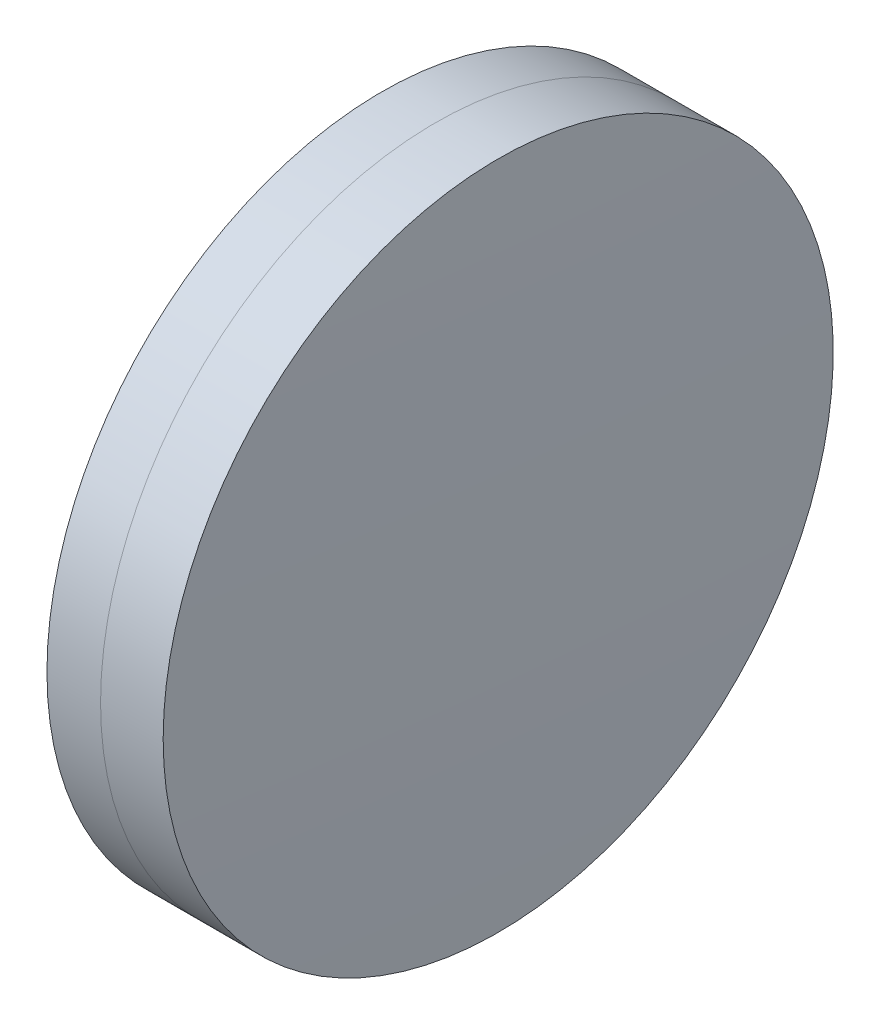
from build123d import *


with BuildPart() as part:
    # 草图1 one side → 旋转1 (revolve)
    with BuildSketch(Plane(origin=(0, 0, 0), x_dir=(1, 0, 0), z_dir=(0, 1, 0)), mode=Mode.PRIVATE) as revolve_1_sk:
        with BuildLine():
            ThreePointArc((174.787921874, 12.5), (174.549245088, 6.25202537), (174.469668974, 0))
            Line((174.469668974, 0), (177.269668974, 0))
            ThreePointArc((177.269668974, 0), (177.149171853, 6.254641088), (176.787859316, 12.5))
            Line((176.787859316, 12.5), (174.787921874, 12.5))
        make_face()
    revolve(revolve_1_sk.sketch.rotate(Axis((-9.702612178, 0, 0), (1, 0, 0)), 180), axis=Axis((-9.702612178, 0, 0), (1, 0, 0)))  # turned: the seam where the file's is


with BuildPart() as body_2:
    # 草图2 one side → 旋转3 (revolve)
    with BuildSketch(Plane(origin=(0, 0, 0), x_dir=(1, 0, 0), z_dir=(0, 1, 0)), mode=Mode.PRIVATE) as revolve_3_sk:
        with BuildLine():
            Line((179.123844569, 12.5), (176.787859316, 12.5))
            ThreePointArc((176.787859316, 12.5), (177.149171853, 6.254641088), (177.269668974, 0))
            Line((177.269668974, 0), (179.269668974, 0))
            ThreePointArc((179.269668974, 0), (179.233211632, 6.250425281), (179.123844569, 12.5))
        make_face()
    revolve(revolve_3_sk.sketch.rotate(Axis((-0.551919993, 0, 0), (1, 0, 0)), 180), axis=Axis((-0.551919993, 0, 0), (1, 0, 0)))  # turned: the seam where the file's is


solid = Compound([part.part, body_2.part])
